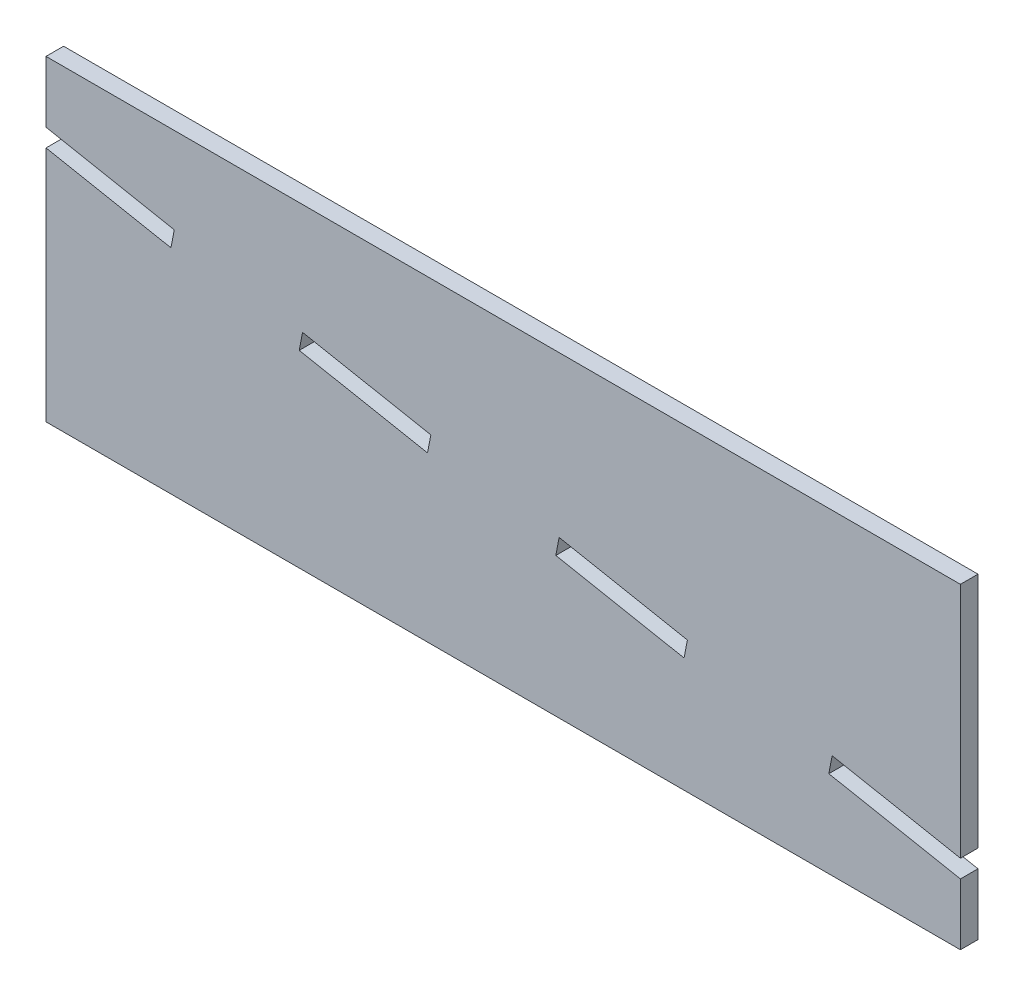
from build123d import *

# Parameters (mm, degrees)
BOSS_EXTRU_1_DEPTH = 5


with BuildPart() as part:
    # Esquisse1 → Boss.-Extru.1 (new body)
    with BuildSketch(Plane.XY):
        Polygon((0, 0), (260, 0), (260, 17.454191866), (222.581237858, 24.650107663), (223.053356342, 27.10512378), (223.525474826, 29.560139898), (260, 22.545808134), (260, 90), (0, 90), (0, 72.545808134), (36.474525174, 65.531476369), (36.002406689, 63.076460252), (35.530288205, 60.621444135), (0, 67.454191866), align=None)
        Polygon((72.476931863, 56.062128488), (72.949050347, 58.517144605), (109.423575521, 51.502812841), (108.951457037, 49.047796724), (108.479338552, 46.592780606), (72.004813379, 53.60711237), align=None, mode=Mode.SUBTRACT)
        Polygon((145.42598221, 42.03346496), (145.898100694, 44.488481077), (182.372625868, 37.474149313), (181.900507384, 35.019133195), (181.4283889, 32.564117078), (144.953863726, 39.578448842), align=None, mode=Mode.SUBTRACT)
    extrude(amount=BOSS_EXTRU_1_DEPTH)


solid = part.part
